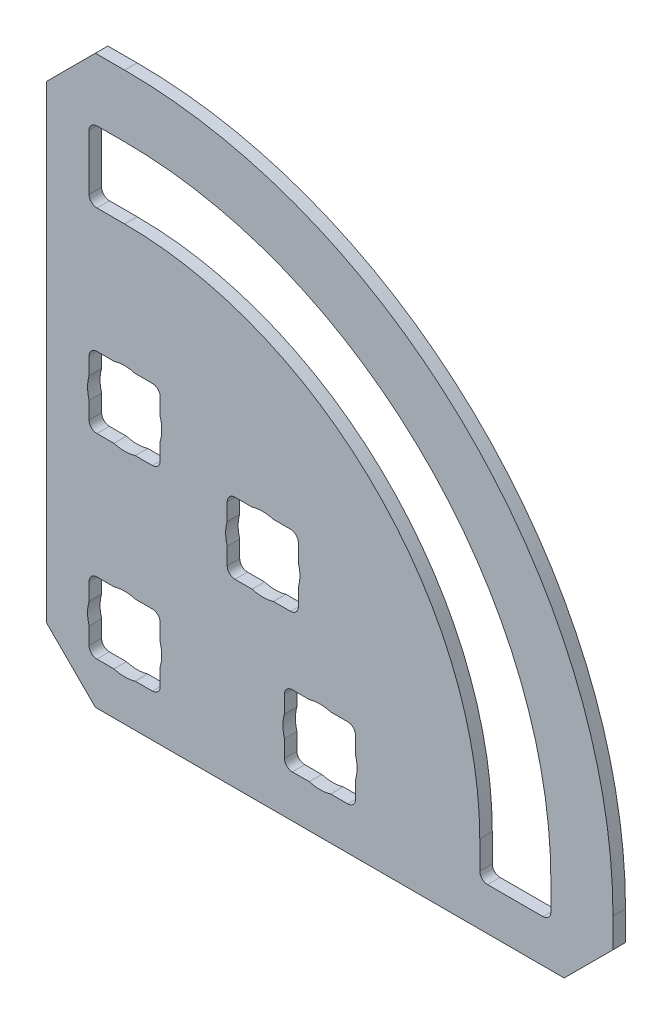
from build123d import *

# Parameters (mm, degrees)
BOSS_EXTRUDE1_DEPTH = 0.8128
SKETCH2_R           = 2.413
CUT_EXTRUDE1_DEPTH  = 2.54


with BuildPart() as part:
    # Sketch1 → Boss-Extrude1 (new body)
    with BuildSketch(Plane.XY.offset(0.8128)):
        with BuildLine():
            Line((-14.966560113, 23.146095061), (-14.966560113, -7.333904636))
            Line((-14.966560113, -7.333904636), (-11.791560113, -10.508904636))
            Line((-11.791560113, -10.508904636), (18.688439584, -10.508904636))
            Line((18.688439584, -10.508904636), (21.863439584, -7.333904636))
            Line((21.863439584, -7.333904636), (21.863439584, -5.428904939))
            ThreePointArc((21.863439584, -5.428904939), (12.564079886, 17.021735364), (-9.886560416, 26.321095061))
            Line((-9.886560416, 26.321095061), (-11.791560113, 26.321095061))
            Line((-11.791560113, 26.321095061), (-14.966560113, 23.146095061))
        make_face()
        with BuildLine():
            Line((17.316839733, -7.740304939), (13.710039804, -7.740304939))
            ThreePointArc((13.710039804, -7.740304939), (13.350829567, -7.591515187), (13.202039815, -7.23230495))
            Line((13.202039815, -7.23230495), (13.202039815, -5.428904939))
            ThreePointArc((13.202039815, -5.428904939), (6.439545376, 10.897200853), (-9.886560416, 17.659695293))
            Line((-9.886560416, 17.659695293), (-11.689960428, 17.659695293))
            ThreePointArc((-11.689960428, 17.659695293), (-12.049170664, 17.808485045), (-12.197960416, 18.167695282))
            Line((-12.197960416, 18.167695282), (-12.197960416, 21.77449521))
            ThreePointArc((-12.197960416, 21.77449521), (-12.049170664, 22.133705447), (-11.689960428, 22.282495199))
            Line((-11.689960428, 22.282495199), (-9.886560416, 22.282495199))
            ThreePointArc((-9.886560416, 22.282495199), (9.708358537, 14.166014015), (17.824839722, -5.428904939))
            Line((17.824839722, -5.428904939), (17.824839722, -7.23230495))
            ThreePointArc((17.824839722, -7.23230495), (17.67604997, -7.591515187), (17.316839733, -7.740304939))
        make_face(mode=Mode.SUBTRACT)
        with BuildLine():
            Line((5.124839584, -3.625504927), (5.124839584, -7.23230495))
            ThreePointArc((5.124839584, -7.23230495), (4.976049832, -7.591515187), (4.616839595, -7.740304939))
            Line((4.616839595, -7.740304939), (1.010039572, -7.740304939))
            ThreePointArc((1.010039572, -7.740304939), (0.650829336, -7.591515187), (0.502039584, -7.23230495))
            Line((0.502039584, -7.23230495), (0.502039584, -3.625504927))
            ThreePointArc((0.502039584, -3.625504927), (0.650829336, -3.266294691), (1.010039572, -3.117504939))
            Line((1.010039572, -3.117504939), (4.616839595, -3.117504939))
            ThreePointArc((4.616839595, -3.117504939), (4.976049832, -3.266294691), (5.124839584, -3.625504927))
        make_face(mode=Mode.SUBTRACT)
        with BuildLine():
            Line((-2.709790428, 5.862665061), (0.897009595, 5.862665061))
            ThreePointArc((0.897009595, 5.862665061), (1.256219832, 5.713875309), (1.405009584, 5.354665073))
            Line((1.405009584, 5.354665073), (1.405009584, 1.74786505))
            ThreePointArc((1.405009584, 1.74786505), (1.256219832, 1.388654813), (0.897009595, 1.239865061))
            Line((0.897009595, 1.239865061), (-2.709790428, 1.239865061))
            ThreePointArc((-2.709790428, 1.239865061), (-3.069000664, 1.388654813), (-3.217790416, 1.74786505))
            Line((-3.217790416, 1.74786505), (-3.217790416, 5.354665073))
            ThreePointArc((-3.217790416, 5.354665073), (-3.069000664, 5.713875309), (-2.709790428, 5.862665061))
        make_face(mode=Mode.SUBTRACT)
        with BuildLine():
            Line((-11.689960428, 9.582495061), (-8.083160405, 9.582495061))
            ThreePointArc((-8.083160405, 9.582495061), (-7.723950168, 9.433705309), (-7.575160416, 9.074495073))
            Line((-7.575160416, 9.074495073), (-7.575160416, 5.46769505))
            ThreePointArc((-7.575160416, 5.46769505), (-7.723950168, 5.108484813), (-8.083160405, 4.959695061))
            Line((-8.083160405, 4.959695061), (-11.689960428, 4.959695061))
            ThreePointArc((-11.689960428, 4.959695061), (-12.049170664, 5.108484813), (-12.197960416, 5.46769505))
            Line((-12.197960416, 5.46769505), (-12.197960416, 9.074495073))
            ThreePointArc((-12.197960416, 9.074495073), (-12.049170664, 9.433705309), (-11.689960428, 9.582495061))
        make_face(mode=Mode.SUBTRACT)
        with BuildLine():
            Line((-8.083160405, -7.740304939), (-11.689960428, -7.740304939))
            ThreePointArc((-11.689960428, -7.740304939), (-12.049170664, -7.591515187), (-12.197960416, -7.23230495))
            Line((-12.197960416, -7.23230495), (-12.197960416, -3.625504927))
            ThreePointArc((-12.197960416, -3.625504927), (-12.049170664, -3.266294691), (-11.689960428, -3.117504939))
            Line((-11.689960428, -3.117504939), (-8.083160405, -3.117504939))
            ThreePointArc((-8.083160405, -3.117504939), (-7.723950168, -3.266294691), (-7.575160416, -3.625504927))
            Line((-7.575160416, -3.625504927), (-7.575160416, -7.23230495))
            ThreePointArc((-7.575160416, -7.23230495), (-7.723950168, -7.591515187), (-8.083160405, -7.740304939))
        make_face(mode=Mode.SUBTRACT)
    extrude(amount=-BOSS_EXTRUDE1_DEPTH)

    # Sketch2 → Cut-Extrude1 (cut)
    with BuildSketch(Plane.XY.offset(0.8128)):
        with Locations((-9.886560416, 7.271095061)):
            Circle(SKETCH2_R)
        with Locations((-0.906390416, 3.551265061)):
            Circle(SKETCH2_R)
        with Locations((2.813439584, -5.428904939)):
            Circle(SKETCH2_R)
        with Locations((-9.886560416, -5.428904939)):
            Circle(SKETCH2_R)
    extrude(amount=-CUT_EXTRUDE1_DEPTH, mode=Mode.SUBTRACT)


solid = part.part
